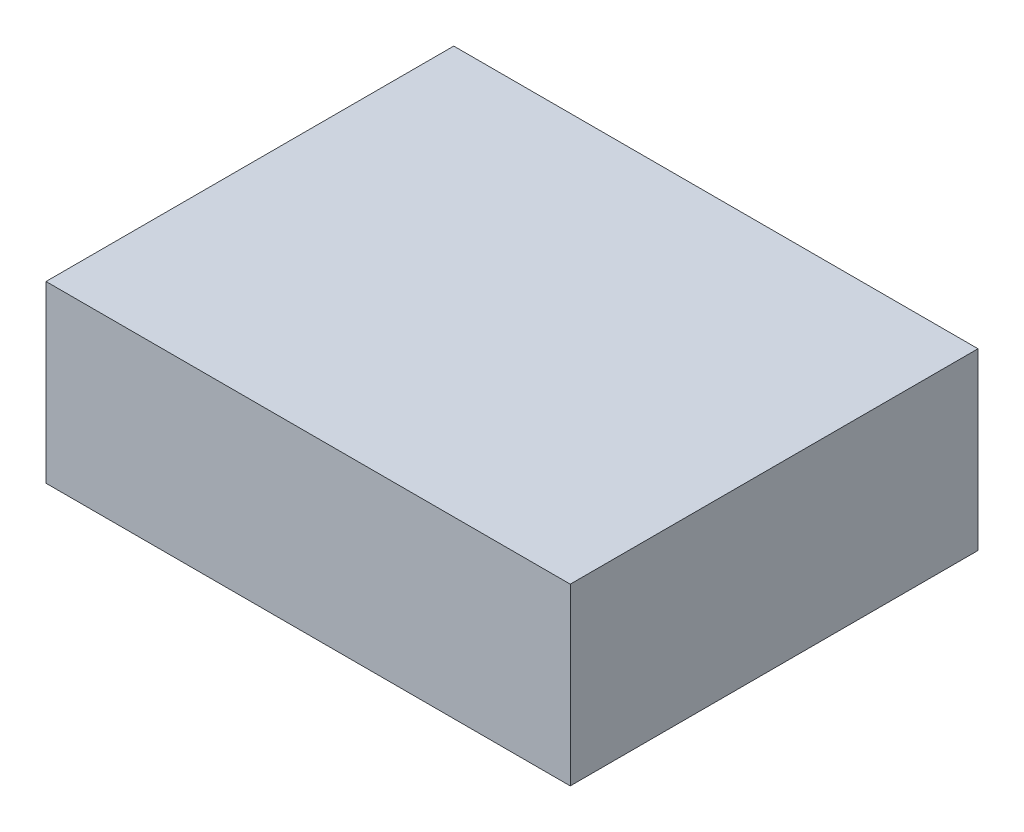
from build123d import *

# Parameters (mm, degrees)
SKETCH1_W           = 114.3
SKETCH1_H           = 88.9
BOSS_EXTRUDE1_DEPTH = 38.1


with BuildPart() as part:
    # Sketch1 → Boss-Extrude1 (new body)
    with BuildSketch(Plane(origin=(0, 0, 0), x_dir=(1, 0, 0), z_dir=(0, 1, 0))):
        with Locations((57.15, 44.45)):
            Rectangle(SKETCH1_W, SKETCH1_H)
    extrude(amount=BOSS_EXTRUDE1_DEPTH)


solid = part.part
